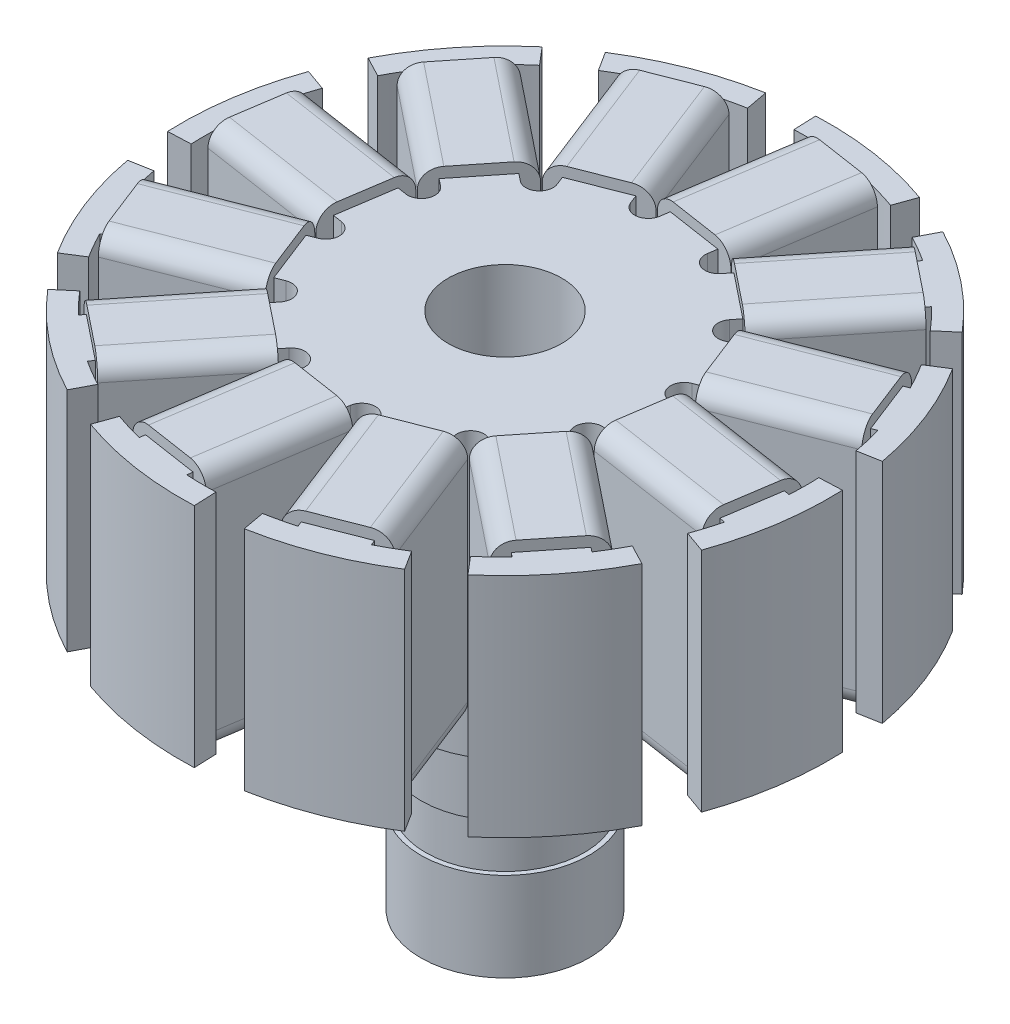
from build123d import *

# Parameters (mm, degrees)
BOSS_EXTRUDE1_DEPTH = 12
SKETCH3_R           = 3
CUT_EXTRUDE1_DEPTH  = 28.405884356
BOSS_EXTRUDE2_START = 0.3
BOSS_EXTRUDE2_DEPTH = 6.8
CIRPATTERN1_COUNT   = 12


with BuildPart() as part:
    # Sketch1 → Revolve1 (revolve)
    with BuildSketch(Plane.XY):
        Polygon((-4.45, 0), (0, 0), (0, 15.405884356), (-5, 15.405884356), (-5, 10.4), (-4.45, 10.4), (-4.45, 7.2), (-4.2, 7.2), (-4.2, 4.7), (-4.45, 4.7), align=None)
    revolve(axis=Axis((0, 15.405884356, 0), (0, -1, 0)))

    # Sketch2 → Boss-Extrude1 (add)
    with BuildSketch(Plane(origin=(0, 15.405884356, 0), x_dir=(1, 0, 0), z_dir=(0, 1, 0))):
        with BuildLine():
            Line((-0.657449307, 15.936444409), (-0.706912578, 17.135424553))
            ThreePointArc((-0.706912578, 17.135424553), (2.575668542, 16.95548382), (5.76360509, 16.152503099))
            Line((5.76360509, 16.152503099), (5.360320769, 15.022298801))
            ThreePointArc((5.360320769, 15.022298801), (4.619591479, 15.266364157), (3.867817265, 15.473929353))
            Line((3.867817265, 15.473929353), (2.727410156, 7.966692316))
            ThreePointArc((2.727410156, 7.966692316), (3.150684675, 7.198740086), (4.002021074, 7.408831212))
            Line((4.002021074, 7.408831212), (8.743261119, 13.340085645))
            ThreePointArc((8.743261119, 13.340085645), (8.080717805, 13.751527179), (7.398854403, 14.130090358))
            Line((7.398854403, 14.130090358), (7.955508026, 15.193169256))
            ThreePointArc((7.955508026, 15.193169256), (10.708336299, 13.396045451), (13.067679975, 11.106675474))
            Line((13.067679975, 11.106675474), (12.153323358, 10.329532))
            ThreePointArc((12.153323358, 10.329532), (11.633865654, 10.911263444), (11.086592685, 11.466907283))
            Line((11.086592685, 11.466907283), (6.34535264, 5.535652851))
            ThreePointArc((6.34535264, 5.535652851), (6.327943011, 4.658949452), (7.170267523, 4.415225505))
            Line((7.170267523, 4.415225505), (14.241929063, 7.181222498))
            ThreePointArc((14.241929063, 7.181222498), (13.873870489, 7.868812976), (13.472641051, 8.537590006))
            Line((13.472641051, 8.537590006), (14.486256678, 9.179916527))
            ThreePointArc((14.486256678, 9.179916527), (15.971713992, 6.247147521), (16.870280563, 3.084823125))
            Line((16.870280563, 3.084823125), (15.689852769, 2.868975442))
            ThreePointArc((15.689852769, 2.868975442), (15.530854923, 3.632498503), (15.334724548, 4.387336668))
            Line((15.334724548, 4.387336668), (8.263063008, 1.621339676))
            ThreePointArc((8.263063008, 1.621339676), (7.809634127, 0.870797075), (8.417246579, 0.23856369))
            Line((8.417246579, 0.23856369), (15.924483616, -0.901843419))
            ThreePointArc((15.924483616, -0.901843419), (15.94953078, -0.12234331), (15.936444409, 0.657449307))
            Line((15.936444409, 0.657449307), (17.135424553, 0.706912578))
            ThreePointArc((17.135424553, 0.706912578), (16.95548382, -2.575668542), (16.152503099, -5.76360509))
            Line((16.152503099, -5.76360509), (15.022298801, -5.360320769))
            ThreePointArc((15.022298801, -5.360320769), (15.266364157, -4.619591479), (15.473929353, -3.867817265))
            Line((15.473929353, -3.867817265), (7.966692316, -2.727410156))
            ThreePointArc((7.966692316, -2.727410156), (7.198740086, -3.150684675), (7.408831212, -4.002021074))
            Line((7.408831212, -4.002021074), (13.340085645, -8.743261119))
            ThreePointArc((13.340085645, -8.743261119), (13.751527179, -8.080717805), (14.130090358, -7.398854403))
            Line((14.130090358, -7.398854403), (15.193169256, -7.955508026))
            ThreePointArc((15.193169256, -7.955508026), (13.396045451, -10.708336299), (11.106675474, -13.067679975))
            Line((11.106675474, -13.067679975), (10.329532, -12.153323358))
            ThreePointArc((10.329532, -12.153323358), (10.911263444, -11.633865654), (11.466907283, -11.086592685))
            Line((11.466907283, -11.086592685), (5.535652851, -6.34535264))
            ThreePointArc((5.535652851, -6.34535264), (4.658949452, -6.327943011), (4.415225505, -7.170267523))
            Line((4.415225505, -7.170267523), (7.181222498, -14.241929063))
            ThreePointArc((7.181222498, -14.241929063), (7.868812976, -13.873870489), (8.537590006, -13.472641051))
            Line((8.537590006, -13.472641051), (9.179916527, -14.486256678))
            ThreePointArc((9.179916527, -14.486256678), (6.247147521, -15.971713992), (3.084823125, -16.870280563))
            Line((3.084823125, -16.870280563), (2.868975442, -15.689852769))
            ThreePointArc((2.868975442, -15.689852769), (3.632498503, -15.530854923), (4.387336668, -15.334724548))
            Line((4.387336668, -15.334724548), (1.621339676, -8.263063008))
            ThreePointArc((1.621339676, -8.263063008), (0.870797075, -7.809634127), (0.23856369, -8.417246579))
            Line((0.23856369, -8.417246579), (-0.901843419, -15.924483616))
            ThreePointArc((-0.901843419, -15.924483616), (-0.12234331, -15.94953078), (0.657449307, -15.936444409))
            Line((0.657449307, -15.936444409), (0.706912578, -17.135424553))
            ThreePointArc((0.706912578, -17.135424553), (-2.575668542, -16.95548382), (-5.76360509, -16.152503099))
            Line((-5.76360509, -16.152503099), (-5.360320769, -15.022298801))
            ThreePointArc((-5.360320769, -15.022298801), (-4.619591479, -15.266364157), (-3.867817265, -15.473929353))
            Line((-3.867817265, -15.473929353), (-2.727410156, -7.966692316))
            ThreePointArc((-2.727410156, -7.966692316), (-3.150684675, -7.198740086), (-4.002021074, -7.408831212))
            Line((-4.002021074, -7.408831212), (-8.743261119, -13.340085645))
            ThreePointArc((-8.743261119, -13.340085645), (-8.080717805, -13.751527179), (-7.398854403, -14.130090358))
            Line((-7.398854403, -14.130090358), (-7.955508026, -15.193169256))
            ThreePointArc((-7.955508026, -15.193169256), (-10.708336299, -13.396045451), (-13.067679975, -11.106675474))
            Line((-13.067679975, -11.106675474), (-12.153323358, -10.329532))
            ThreePointArc((-12.153323358, -10.329532), (-11.633865654, -10.911263444), (-11.086592685, -11.466907283))
            Line((-11.086592685, -11.466907283), (-6.34535264, -5.535652851))
            ThreePointArc((-6.34535264, -5.535652851), (-6.327943011, -4.658949452), (-7.170267523, -4.415225505))
            Line((-7.170267523, -4.415225505), (-14.241929063, -7.181222498))
            ThreePointArc((-14.241929063, -7.181222498), (-13.873870489, -7.868812976), (-13.472641051, -8.537590006))
            Line((-13.472641051, -8.537590006), (-14.486256678, -9.179916527))
            ThreePointArc((-14.486256678, -9.179916527), (-15.971713992, -6.247147521), (-16.870280563, -3.084823125))
            Line((-16.870280563, -3.084823125), (-15.689852769, -2.868975442))
            ThreePointArc((-15.689852769, -2.868975442), (-15.530854923, -3.632498503), (-15.334724548, -4.387336668))
            Line((-15.334724548, -4.387336668), (-8.263063008, -1.621339676))
            ThreePointArc((-8.263063008, -1.621339676), (-7.809634127, -0.870797075), (-8.417246579, -0.23856369))
            Line((-8.417246579, -0.23856369), (-15.924483616, 0.901843419))
            ThreePointArc((-15.924483616, 0.901843419), (-15.94953078, 0.12234331), (-15.936444409, -0.657449307))
            Line((-15.936444409, -0.657449307), (-17.135424553, -0.706912578))
            ThreePointArc((-17.135424553, -0.706912578), (-16.95548382, 2.575668542), (-16.152503099, 5.76360509))
            Line((-16.152503099, 5.76360509), (-15.022298801, 5.360320769))
            ThreePointArc((-15.022298801, 5.360320769), (-15.266364157, 4.619591479), (-15.473929353, 3.867817265))
            Line((-15.473929353, 3.867817265), (-7.966692316, 2.727410156))
            ThreePointArc((-7.966692316, 2.727410156), (-7.198740086, 3.150684675), (-7.408831212, 4.002021074))
            Line((-7.408831212, 4.002021074), (-13.340085645, 8.743261119))
            ThreePointArc((-13.340085645, 8.743261119), (-13.751527179, 8.080717805), (-14.130090358, 7.398854403))
            Line((-14.130090358, 7.398854403), (-15.193169256, 7.955508026))
            ThreePointArc((-15.193169256, 7.955508026), (-13.396045451, 10.708336299), (-11.106675474, 13.067679975))
            Line((-11.106675474, 13.067679975), (-10.329532, 12.153323358))
            ThreePointArc((-10.329532, 12.153323358), (-10.911263444, 11.633865654), (-11.466907283, 11.086592685))
            Line((-11.466907283, 11.086592685), (-5.535652851, 6.34535264))
            ThreePointArc((-5.535652851, 6.34535264), (-4.658949452, 6.327943011), (-4.415225505, 7.170267523))
            Line((-4.415225505, 7.170267523), (-7.181222498, 14.241929063))
            ThreePointArc((-7.181222498, 14.241929063), (-7.868812976, 13.873870489), (-8.537590006, 13.472641051))
            Line((-8.537590006, 13.472641051), (-9.179916527, 14.486256678))
            ThreePointArc((-9.179916527, 14.486256678), (-6.247147521, 15.971713992), (-3.084823125, 16.870280563))
            Line((-3.084823125, 16.870280563), (-2.868975442, 15.689852769))
            ThreePointArc((-2.868975442, 15.689852769), (-3.632498503, 15.530854923), (-4.387336668, 15.334724548))
            Line((-4.387336668, 15.334724548), (-1.621339676, 8.263063008))
            ThreePointArc((-1.621339676, 8.263063008), (-0.870797075, 7.809634127), (-0.23856369, 8.417246579))
            Line((-0.23856369, 8.417246579), (0.901843419, 15.924483616))
            ThreePointArc((0.901843419, 15.924483616), (0.12234331, 15.94953078), (-0.657449307, 15.936444409))
        make_face()
    extrude(amount=BOSS_EXTRUDE1_DEPTH)

    # Sketch3 → Cut-Extrude1 (cut, through all)
    with BuildSketch(Plane(origin=(0, 27.405884356, 0), x_dir=(1, 0, 0), z_dir=(0, 1, 0))):
        Circle(SKETCH3_R)
    extrude(amount=-CUT_EXTRUDE1_DEPTH, mode=Mode.SUBTRACT)

    # Sketch5 → Boss-Extrude2 (add)
    with BuildSketch(Plane(origin=(-15.699206484, 0, -2.384830342), x_dir=(0.150184755, 0, -0.988657949), z_dir=(0.988657949, 0, 0.150184755)).offset(BOSS_EXTRUDE2_START)):
        with BuildLine():
            Line((1.321894274, 14.856274232), (-1.321894274, 14.856274232))
            ThreePointArc((-1.321894274, 14.856274232), (-2.029001055, 15.149167451), (-2.321894274, 15.856274232))
            Line((-2.321894274, 15.856274232), (-2.321894274, 26.95549448))
            ThreePointArc((-2.321894274, 26.95549448), (-2.029001055, 27.662601261), (-1.321894274, 27.95549448))
            Line((-1.321894274, 27.95549448), (1.321894274, 27.95549448))
            ThreePointArc((1.321894274, 27.95549448), (2.029001055, 27.662601261), (2.321894274, 26.95549448))
            Line((2.321894274, 26.95549448), (2.321894274, 15.856274232))
            ThreePointArc((2.321894274, 15.856274232), (2.029001055, 15.149167451), (1.321894274, 14.856274232))
        make_face()
    boss_extrude2 = extrude(amount=BOSS_EXTRUDE2_DEPTH)

    # CirPattern1: Boss-Extrude2 ×12 about axis
    cirpattern1_axis = Axis((0, 0, 0), (0, 1, 0))
    for i in range(1, CIRPATTERN1_COUNT):
        add(boss_extrude2.rotate(cirpattern1_axis, i * 360 / CIRPATTERN1_COUNT))


solid = part.part
